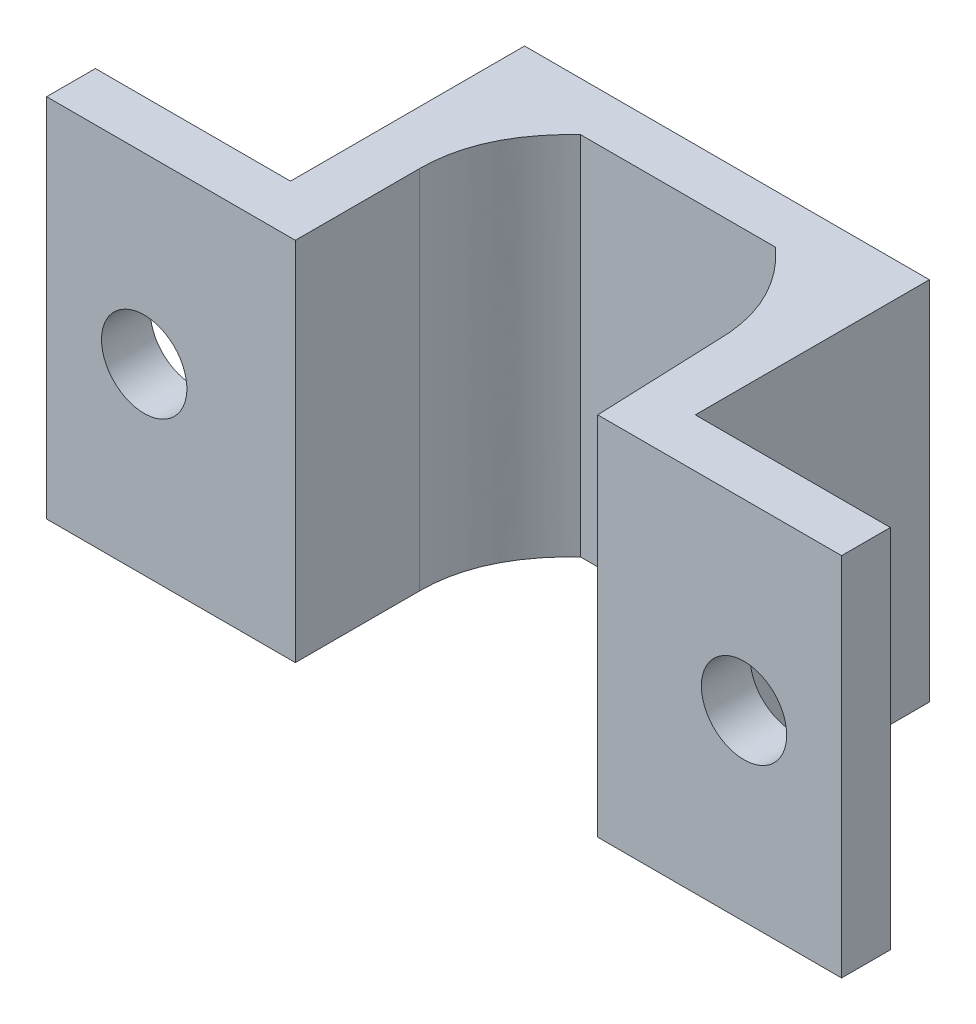
from build123d import *

# Parameters (mm, degrees)
BOSS_EXTRUDE1_DEPTH = 15
SKETCH2_R           = 1.75
CUT_EXTRUDE1_DEPTH  = 15


with BuildPart() as part:
    # Sketch1 → Boss-Extrude1 (new body)
    with BuildSketch(Plane(origin=(0, 0, 0), x_dir=(1, 0, 0), z_dir=(0, 1, 0))):
        with BuildLine():
            Line((12.4, 5.1), (12.6, 0))
            Line((12.6, 0), (22.6, 0))
            Line((22.6, 0), (22.6, 2))
            Line((22.6, 2), (14.6, 2))
            Line((14.6, 2), (14.6, 11.6))
            Line((14.6, 11.6), (-2, 11.6))
            Line((-2, 11.6), (-2, 2))
            Line((-2, 2), (-10, 2))
            Line((-10, 2), (-10, 0))
            Line((-10, 0), (0, 0))
            Line((0, 0), (0.2, 0))
            Line((0.2, 0), (0.2, 5.1))
            add(Edge.make_bspline(
                [(2.3, 9.6), (0.2, 7.65), (0.2, 5.1)],
                knots=[0, 0, 0, 0.5, 0.5, 0.5], degree=2))
            Line((2.3, 9.6), (10.3, 9.6))
            add(Edge.make_bspline(
                [(10.3, 9.6), (12.4, 7.65), (12.4, 5.1)],
                knots=[0, 0, 0, 0.5, 0.5, 0.5], degree=2))
        make_face()
    extrude(amount=BOSS_EXTRUDE1_DEPTH)

    # Sketch2 → Cut-Extrude1 (cut)
    with BuildSketch(Plane(origin=(0, 0, -2), x_dir=(-1, 0, 0), z_dir=(0, 0, -1))):
        with Locations((-18.6, 7.5)):
            Circle(SKETCH2_R)
        with Locations((6, 7.5)):
            Circle(SKETCH2_R)
    extrude(amount=-CUT_EXTRUDE1_DEPTH, mode=Mode.SUBTRACT)


solid = part.part
